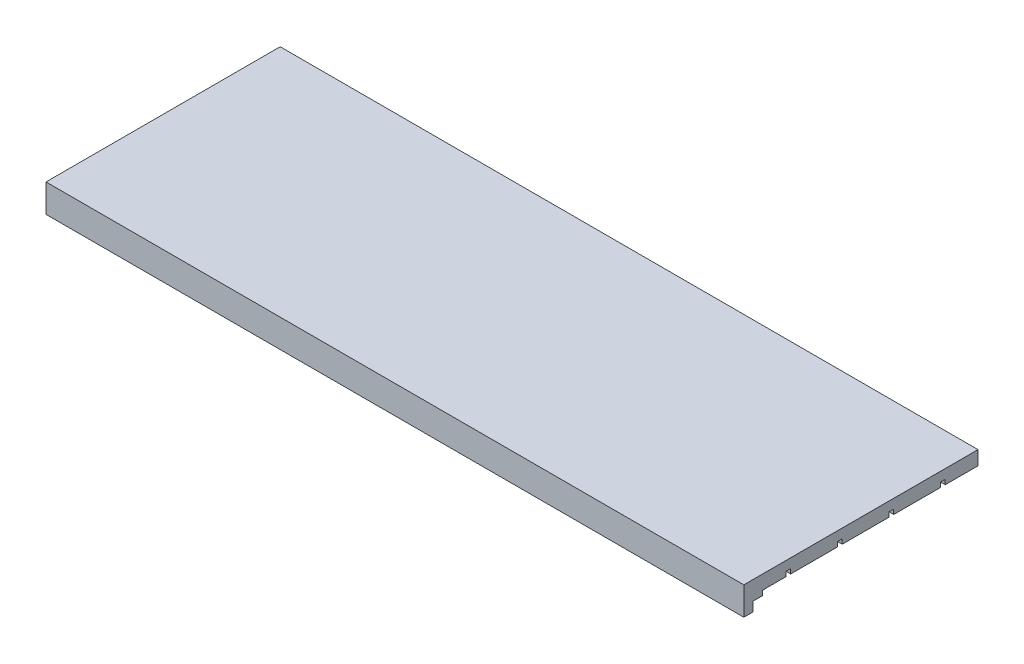
from build123d import *

# Parameters (mm, degrees)
SKETCH1_W           = 149
SKETCH1_H           = 50
BOSS_EXTRUDE1_DEPTH = 3
SKETCH2_W           = 149
SKETCH2_H           = 1
CUT_EXTRUDE1_DEPTH  = 1
SKETCH3_W           = 149
SKETCH3_H           = 4
BOSS_EXTRUDE2_DEPTH = 1
SKETCH4_W           = 149
SKETCH4_H           = 2
BOSS_EXTRUDE3_DEPTH = 2


with BuildPart() as part:
    # Sketch1 → Boss-Extrude1 (new body)
    with BuildSketch(Plane(origin=(0, 0, 0), x_dir=(1, 0, 0), z_dir=(0, 1, 0))):
        Rectangle(SKETCH1_W, SKETCH1_H)
    extrude(amount=BOSS_EXTRUDE1_DEPTH)

    # Sketch2 → Cut-Extrude1 (cut)
    with BuildSketch(Plane.XZ):
        with Locations((0, -17.5)):
            Rectangle(SKETCH2_W, SKETCH2_H)
        with Locations((0, -6.5)):
            Rectangle(SKETCH2_W, SKETCH2_H)
        with Locations((0, 4.5)):
            Rectangle(SKETCH2_W, SKETCH2_H)
        with Locations((0, 15.5)):
            Rectangle(SKETCH2_W, SKETCH2_H)
    extrude(amount=-CUT_EXTRUDE1_DEPTH, mode=Mode.SUBTRACT)

    # Sketch3 → Boss-Extrude2 (add)
    with BuildSketch(Plane.XZ):
        with Locations((0, 23)):
            Rectangle(SKETCH3_W, SKETCH3_H)
    extrude(amount=BOSS_EXTRUDE2_DEPTH)

    # Sketch4 → Boss-Extrude3 (add)
    with BuildSketch(Plane.XZ.offset(1)):
        with Locations((0, 24)):
            Rectangle(SKETCH4_W, SKETCH4_H)
    extrude(amount=BOSS_EXTRUDE3_DEPTH)


solid = part.part
